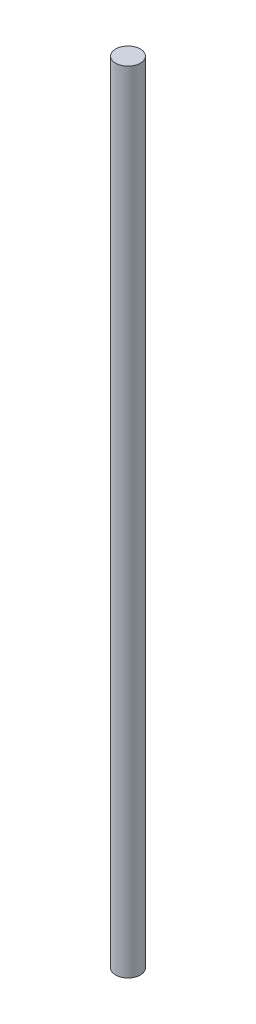
from build123d import *

# Parameters (mm, degrees)
SKETCH1_R           = 1.5875
BOSS_EXTRUDE1_DEPTH = 101.6


with BuildPart() as part:
    # Sketch1 → Boss-Extrude1 (new body)
    with BuildSketch(Plane(origin=(0, 0, 0), x_dir=(1, 0, 0), z_dir=(0, 1, 0))):
        with Locations(Location((0, 0, 0), (0, 0, 270))):  # turned: the seam where the file's is
            Circle(SKETCH1_R)
    extrude(amount=BOSS_EXTRUDE1_DEPTH)


solid = part.part
